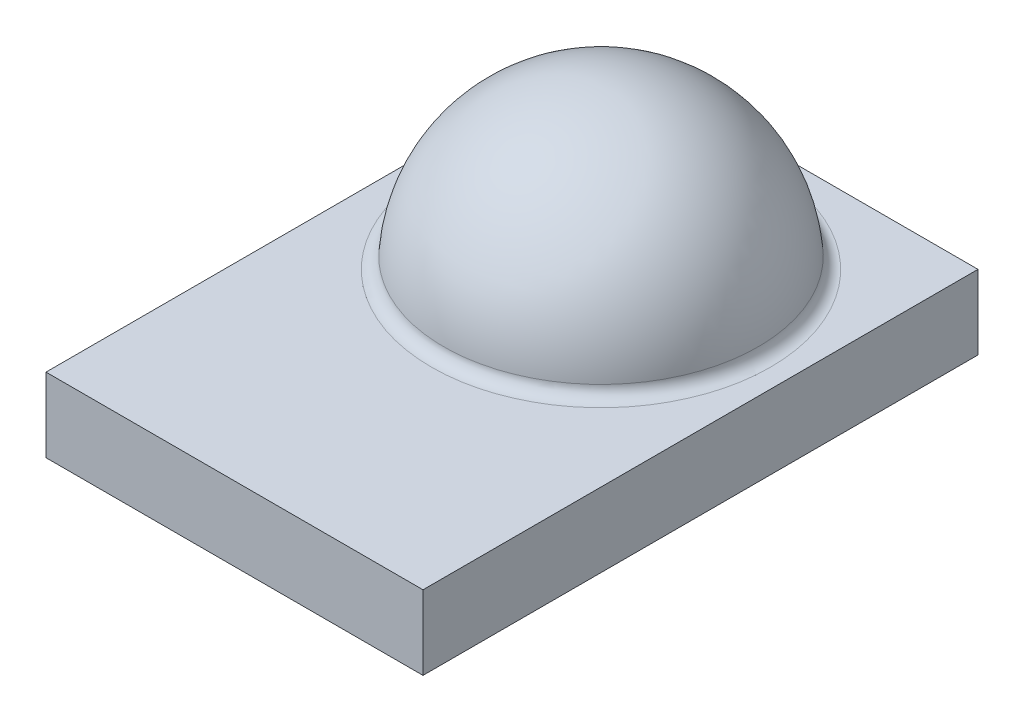
from build123d import *

# Parameters (mm, degrees)
SKETCH1_W           = 3.05
SKETCH1_H           = 4.49
BOSS_EXTRUDE1_DEPTH = 0.6
REVOLVE1_ANGLE      = 180
FILLET1_R           = 0.1
SKETCH3_W           = 2.8
SKETCH3_H           = 1.77
SKETCH3_W_2         = 1.2
SKETCH3_H_2         = 0.67
BOSS_EXTRUDE2_DEPTH = 0.08


with BuildPart() as part:
    # Sketch1 → Boss-Extrude1 (new body)
    with BuildSketch(Plane(origin=(0, 0, 0), x_dir=(1, 0, 0), z_dir=(0, 1, 0))):
        with Locations((1.525, 2.245)):
            Rectangle(SKETCH1_W, SKETCH1_H)
    extrude(amount=BOSS_EXTRUDE1_DEPTH)

    # Sketch2 → Revolve1 (revolve)
    with BuildSketch(Plane(origin=(0, 0.6, 0), x_dir=(1, 0, 0), z_dir=(0, 1, 0))):
        with BuildLine():
            Line((0.25, 2.965), (2.8, 2.965))
            ThreePointArc((2.8, 2.965), (1.525, 4.24), (0.25, 2.965))
        make_face()
    revolve(axis=Axis((0.25, 0.6, -2.965), (1, 0, 0)), revolution_arc=REVOLVE1_ANGLE)

    # Fillet1
    fillet1_edges = [part.edges().sort_by_distance(p)[0] for p in [
        (1.525, 0.6, -4.24),
    ]]
    fillet(fillet1_edges, radius=FILLET1_R)

    # Sketch3 → Boss-Extrude2 (add)
    with BuildSketch(Plane.XZ):
        with Locations((1.525, -3.48)):
            Rectangle(SKETCH3_W, SKETCH3_H)
        with Locations((0.725, -0.46)):
            Rectangle(SKETCH3_W_2, SKETCH3_H_2)
        with Locations((2.325, -0.46)):
            Rectangle(SKETCH3_W_2, SKETCH3_H_2)
    extrude(amount=BOSS_EXTRUDE2_DEPTH)


solid = part.part
